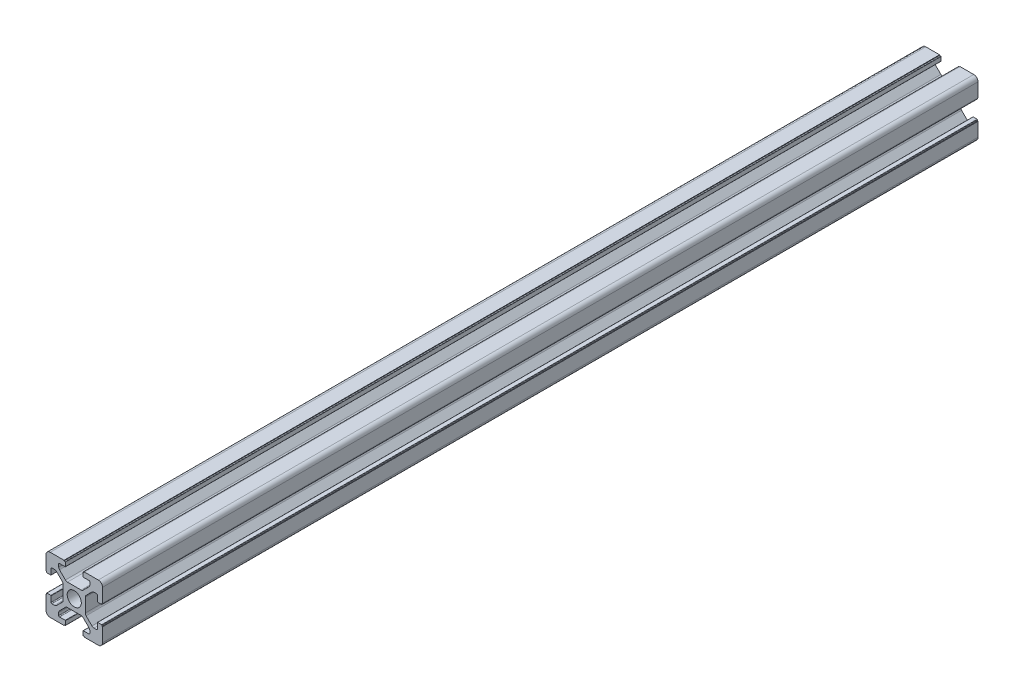
from build123d import *

# Parameters (mm, degrees)
SKETCH_1_R      = 2.5
EXTRUDE_1_DEPTH = 310
FILLET_1_R      = 1.5


with BuildPart() as part:
    # 草图1 → 凸台-拉伸1 (new body)
    with BuildSketch(Plane.XY):
        with BuildLine():
            Line((20, 13.6), (20, 20))
            Line((20, 20), (13.6, 20))
            Line((13.6, 20), (13.6, 19.8))
            Line((13.6, 19.8), (13.2, 19.8))
            ThreePointArc((13.2, 19.8), (13.129289322, 19.770710678), (13.1, 19.7))
            Line((13.1, 19.7), (13.1, 18.3))
            ThreePointArc((13.1, 18.3), (13.129289322, 18.229289322), (13.2, 18.2))
            Line((13.2, 18.2), (15.2, 18.2))
            ThreePointArc((15.2, 18.2), (15.412132034, 18.112132034), (15.5, 17.9))
            Line((15.5, 17.9), (15.5, 16.974873734))
            ThreePointArc((15.5, 16.974873734), (15.423879533, 16.592190302), (15.207106781, 16.267766953))
            Line((15.207106781, 16.267766953), (13.132233047, 14.192893219))
            ThreePointArc((13.132233047, 14.192893219), (12.807809698, 13.976120467), (12.425126266, 13.9))
            Line((12.425126266, 13.9), (7.574873734, 13.9))
            ThreePointArc((7.574873734, 13.9), (7.192190302, 13.976120467), (6.867766953, 14.192893219))
            Line((6.867766953, 14.192893219), (4.792893219, 16.267766953))
            ThreePointArc((4.792893219, 16.267766953), (4.576120467, 16.592190302), (4.5, 16.974873734))
            Line((4.5, 16.974873734), (4.5, 17.9))
            ThreePointArc((4.5, 17.9), (4.587867966, 18.112132034), (4.8, 18.2))
            Line((4.8, 18.2), (6.8, 18.2))
            ThreePointArc((6.8, 18.2), (6.870710678, 18.229289322), (6.9, 18.3))
            Line((6.9, 18.3), (6.9, 19.7))
            ThreePointArc((6.9, 19.7), (6.870710678, 19.770710678), (6.8, 19.8))
            Line((6.8, 19.8), (6.4, 19.8))
            Line((6.4, 19.8), (6.4, 20))
            Line((6.4, 20), (0, 20))
            Line((0, 20), (0, 13.6))
            Line((0, 13.6), (0.2, 13.6))
            Line((0.2, 13.6), (0.2, 13.2))
            ThreePointArc((0.2, 13.2), (0.229289322, 13.129289322), (0.3, 13.1))
            Line((0.3, 13.1), (1.7, 13.1))
            ThreePointArc((1.7, 13.1), (1.770710678, 13.129289322), (1.8, 13.2))
            Line((1.8, 13.2), (1.8, 15.2))
            ThreePointArc((1.8, 15.2), (1.887867966, 15.412132034), (2.1, 15.5))
            Line((2.1, 15.5), (3.025126266, 15.5))
            ThreePointArc((3.025126266, 15.5), (3.407809698, 15.423879533), (3.732233047, 15.207106781))
            Line((3.732233047, 15.207106781), (5.807106781, 13.132233047))
            ThreePointArc((5.807106781, 13.132233047), (6.023879533, 12.807809698), (6.1, 12.425126266))
            Line((6.1, 12.425126266), (6.1, 7.574873734))
            ThreePointArc((6.1, 7.574873734), (6.023879533, 7.192190302), (5.807106781, 6.867766953))
            Line((5.807106781, 6.867766953), (3.732233047, 4.792893219))
            ThreePointArc((3.732233047, 4.792893219), (3.407809698, 4.576120467), (3.025126266, 4.5))
            Line((3.025126266, 4.5), (2.1, 4.5))
            ThreePointArc((2.1, 4.5), (1.887867966, 4.587867966), (1.8, 4.8))
            Line((1.8, 4.8), (1.8, 6.8))
            ThreePointArc((1.8, 6.8), (1.770710678, 6.870710678), (1.7, 6.9))
            Line((1.7, 6.9), (0.3, 6.9))
            ThreePointArc((0.3, 6.9), (0.229289322, 6.870710678), (0.2, 6.8))
            Line((0.2, 6.8), (0.2, 6.4))
            Line((0.2, 6.4), (0, 6.4))
            Line((0, 6.4), (0, 0))
            Line((0, 0), (6.4, 0))
            Line((6.4, 0), (6.4, 0.2))
            Line((6.4, 0.2), (6.8, 0.2))
            ThreePointArc((6.8, 0.2), (6.870710678, 0.229289322), (6.9, 0.3))
            Line((6.9, 0.3), (6.9, 1.7))
            ThreePointArc((6.9, 1.7), (6.870710678, 1.770710678), (6.8, 1.8))
            Line((6.8, 1.8), (4.8, 1.8))
            ThreePointArc((4.8, 1.8), (4.587867966, 1.887867966), (4.5, 2.1))
            Line((4.5, 2.1), (4.5, 3.025126266))
            ThreePointArc((4.5, 3.025126266), (4.576120467, 3.407809698), (4.792893219, 3.732233047))
            Line((4.792893219, 3.732233047), (6.867766953, 5.807106781))
            ThreePointArc((6.867766953, 5.807106781), (7.192190302, 6.023879533), (7.574873734, 6.1))
            Line((7.574873734, 6.1), (12.425126266, 6.1))
            ThreePointArc((12.425126266, 6.1), (12.807809698, 6.023879533), (13.132233047, 5.807106781))
            Line((13.132233047, 5.807106781), (15.207106781, 3.732233047))
            ThreePointArc((15.207106781, 3.732233047), (15.423879533, 3.407809698), (15.5, 3.025126266))
            Line((15.5, 3.025126266), (15.5, 2.1))
            ThreePointArc((15.5, 2.1), (15.412132034, 1.887867966), (15.2, 1.8))
            Line((15.2, 1.8), (13.2, 1.8))
            ThreePointArc((13.2, 1.8), (13.129289322, 1.770710678), (13.1, 1.7))
            Line((13.1, 1.7), (13.1, 0.3))
            ThreePointArc((13.1, 0.3), (13.129289322, 0.229289322), (13.2, 0.2))
            Line((13.2, 0.2), (13.6, 0.2))
            Line((13.6, 0.2), (13.6, 0))
            Line((13.6, 0), (20, 0))
            Line((20, 0), (20, 6.4))
            Line((20, 6.4), (19.8, 6.4))
            Line((19.8, 6.4), (19.8, 6.8))
            ThreePointArc((19.8, 6.8), (19.770710678, 6.870710678), (19.7, 6.9))
            Line((19.7, 6.9), (18.3, 6.9))
            ThreePointArc((18.3, 6.9), (18.229289322, 6.870710678), (18.2, 6.8))
            Line((18.2, 6.8), (18.2, 4.8))
            ThreePointArc((18.2, 4.8), (18.112132034, 4.587867966), (17.9, 4.5))
            Line((17.9, 4.5), (16.974873734, 4.5))
            ThreePointArc((16.974873734, 4.5), (16.592190302, 4.576120467), (16.267766953, 4.792893219))
            Line((16.267766953, 4.792893219), (14.192893219, 6.867766953))
            ThreePointArc((14.192893219, 6.867766953), (13.976120467, 7.192190302), (13.9, 7.574873734))
            Line((13.9, 7.574873734), (13.9, 12.425126266))
            ThreePointArc((13.9, 12.425126266), (13.976120467, 12.807809698), (14.192893219, 13.132233047))
            Line((14.192893219, 13.132233047), (16.267766953, 15.207106781))
            ThreePointArc((16.267766953, 15.207106781), (16.592190302, 15.423879533), (16.974873734, 15.5))
            Line((16.974873734, 15.5), (17.9, 15.5))
            ThreePointArc((17.9, 15.5), (18.112132034, 15.412132034), (18.2, 15.2))
            Line((18.2, 15.2), (18.2, 13.2))
            ThreePointArc((18.2, 13.2), (18.229289322, 13.129289322), (18.3, 13.1))
            Line((18.3, 13.1), (19.7, 13.1))
            ThreePointArc((19.7, 13.1), (19.770710678, 13.129289322), (19.8, 13.2))
            Line((19.8, 13.2), (19.8, 13.6))
            Line((19.8, 13.6), (20, 13.6))
        make_face()
        with Locations((10, 10)):
            Circle(SKETCH_1_R, mode=Mode.SUBTRACT)
    extrude(amount=EXTRUDE_1_DEPTH)

    # 圆角1
    fillet_1_edges = [part.edges().sort_by_distance(p)[0] for p in [
        (0, 0, 155),
        (0, 20, 155),
        (20, 20, 155),
        (20, 0, 155),
    ]]
    fillet(fillet_1_edges, radius=FILLET_1_R)


solid = part.part
